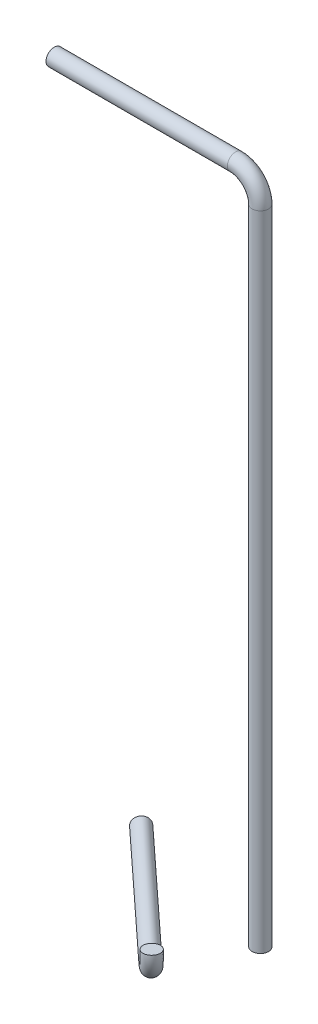
from build123d import *

# Parameters (mm, degrees)
SKETCH3_R = 1
SKETCH6_R = 1


with BuildPart() as part:
    # Sweep1: sweep along a path in Sketch1
    with BuildLine(Plane.XY) as sweep1_path:
        Line((0, 0), (22, 0))
        ThreePointArc((22, 0), (24.121320344, -0.878679656), (25, -3))
        Line((25, -3), (25, -81.02))
    # Sketch3 → Sweep1 (sweep)
    with BuildSketch(Plane(origin=(0, 0, 0), x_dir=(0, 0, -1), z_dir=(1, 0, 0))):
        Circle(SKETCH3_R)
    sweep(path=sweep1_path.line)


with BuildPart() as body_2:
    # Sweep3: sweep along a path in Sketch4
    with BuildLine(Plane(origin=(5.187924196, 0, -5.613163884), x_dir=(-0.7343767081251095, 0, -0.6787421090247221), z_dir=(0.6787421090247221, 0, -0.7343767081251095))) as sweep3_path:
        Line((4.63156326, -84.252449737), (-15.36843674, -84.252449737))
        ThreePointArc((-15.36843674, -84.252449737), (-17.570407359, -83.289929895), (-18.359417703, -81.02))
    # Sketch6 → Sweep3 (sweep)
    with BuildSketch(Plane(origin=(1.786612015, -84.252449737, -8.756800899), x_dir=(-0.6787421090247221, 0, 0.7343767081251096), z_dir=(-0.7343767081251096, 0, -0.6787421090247221))):
        Circle(SKETCH6_R)
    sweep(path=sweep3_path.line)


solid = Compound([part.part, body_2.part])
